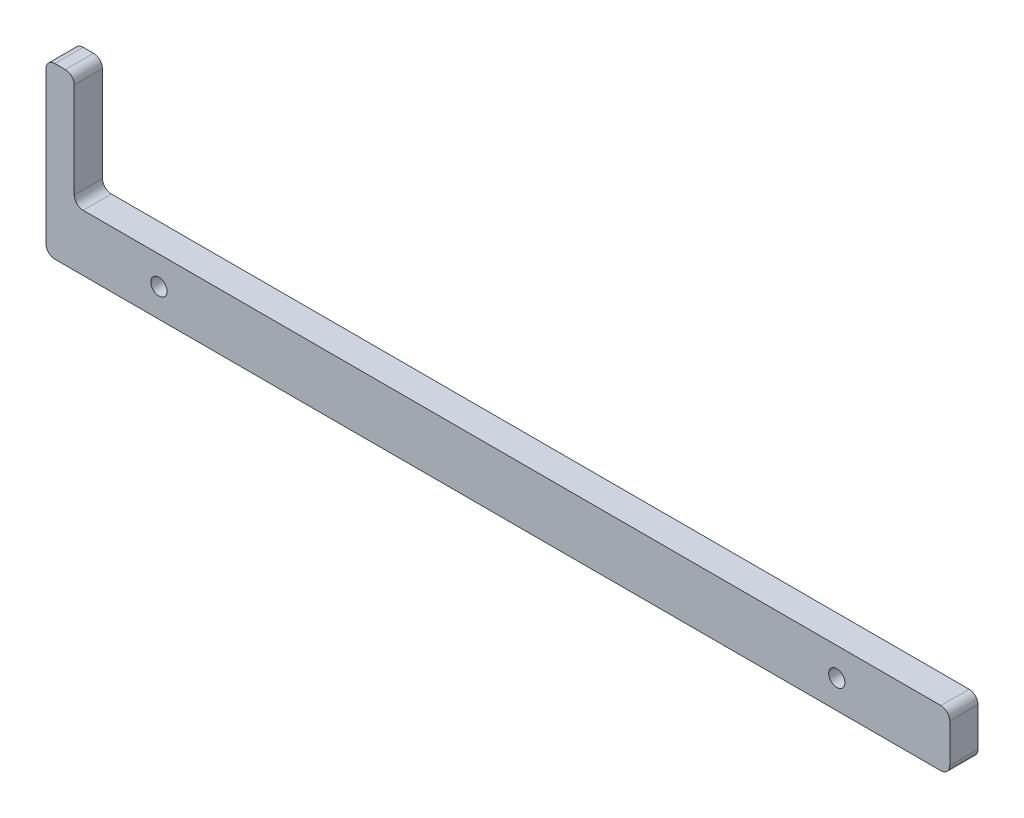
from build123d import *

# Parameters (mm, degrees)
SKETCH2_W                 = 203.2
SKETCH2_H                 = 12.7
BOSS_EXTRUDE1_DEPTH       = 6.35
SKETCH3_W                 = 6.35
SKETCH3_H                 = 6.35
BOSS_EXTRUDE2_DEPTH       = 25.4
FILLET2_R                 = 2
F_6_CLEARANCE_HOLE1_D     = 3.6576
F_6_CLEARANCE_HOLE1_DEPTH = 10.16
F_6_CLEARANCE_HOLE1_TIP   = 1.0988539


with BuildPart() as part:
    # Sketch2 → Boss-Extrude1 (new body)
    with BuildSketch(Plane.XY):
        with Locations((101.6, 6.35)):
            Rectangle(SKETCH2_W, SKETCH2_H)
    extrude(amount=BOSS_EXTRUDE1_DEPTH)

    # Sketch3 → Boss-Extrude2 (add)
    with BuildSketch(Plane(origin=(0, 12.7, 0), x_dir=(1, 0, 0), z_dir=(0, 1, 0))):
        with Locations((3.175, -3.175)):
            Rectangle(SKETCH3_W, SKETCH3_H)
    extrude(amount=BOSS_EXTRUDE2_DEPTH)

    # Fillet2
    fillet2_edges = [part.edges().sort_by_distance(p)[0] for p in [
        (6.35, 12.7, 3.175),
        (0, 38.1, 3.175),
        (6.35, 38.1, 3.175),
        (203.2, 12.7, 3.175),
        (203.2, 0, 3.175),
        (0, 0, 3.175),
    ]]
    fillet(fillet2_edges, radius=FILLET2_R)

    # #6 Clearance Hole1
    with Locations(Plane.XY.offset(6.35)):
        with Locations((177.8, 6.35), (25.4, 6.35)):
            Hole(F_6_CLEARANCE_HOLE1_D / 2, depth=F_6_CLEARANCE_HOLE1_DEPTH)
            with Locations((0, 0, -(F_6_CLEARANCE_HOLE1_DEPTH + F_6_CLEARANCE_HOLE1_TIP / 2))):  # 118° drill point
                Cone(0, F_6_CLEARANCE_HOLE1_D / 2, F_6_CLEARANCE_HOLE1_TIP, mode=Mode.SUBTRACT)


solid = part.part
